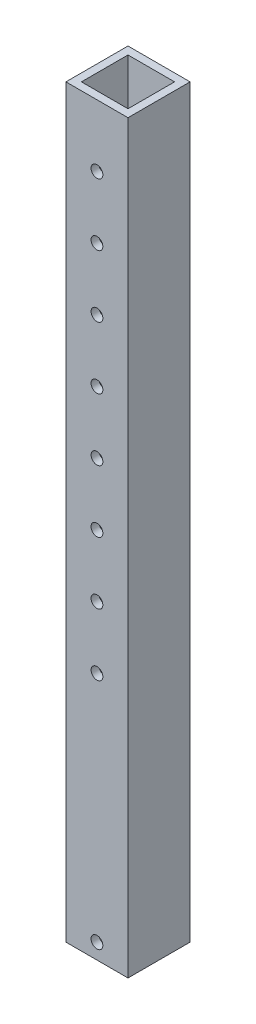
from build123d import *

# Parameters (mm, degrees)
SKETCH2_W           = 50.8
SKETCH2_H           = 50.8
SKETCH2_W_2         = 38.1
SKETCH2_H_2         = 38.1
BOSS_EXTRUDE1_DEPTH = 609.6
SKETCH3_R           = 4.826
CUT_EXTRUDE1_DEPTH  = 609.6


with BuildPart() as part:
    # Sketch2 → Boss-Extrude1 (new body)
    with BuildSketch(Plane(origin=(0, 0, 0), x_dir=(1, 0, 0), z_dir=(0, 1, 0))):
        Rectangle(SKETCH2_W, SKETCH2_H)
        Rectangle(SKETCH2_W_2, SKETCH2_H_2, mode=Mode.SUBTRACT)
    extrude(amount=BOSS_EXTRUDE1_DEPTH)

    # Sketch3 → Cut-Extrude1 (cut)
    with BuildSketch(Plane.XY.offset(25.4)):
        with Locations((0, 12.7)):
            Circle(SKETCH3_R)
        with Locations((0, 558.8)):
            Circle(SKETCH3_R)
        with Locations((0, 508)):
            Circle(SKETCH3_R)
        with Locations((0, 457.2)):
            Circle(SKETCH3_R)
        with Locations((0, 406.4)):
            Circle(SKETCH3_R)
        with Locations((0, 355.6)):
            Circle(SKETCH3_R)
        with Locations((0, 304.8)):
            Circle(SKETCH3_R)
        with Locations((0, 254)):
            Circle(SKETCH3_R)
        with Locations((0, 203.2)):
            Circle(SKETCH3_R)
    extrude(amount=-CUT_EXTRUDE1_DEPTH, mode=Mode.SUBTRACT)


solid = part.part
